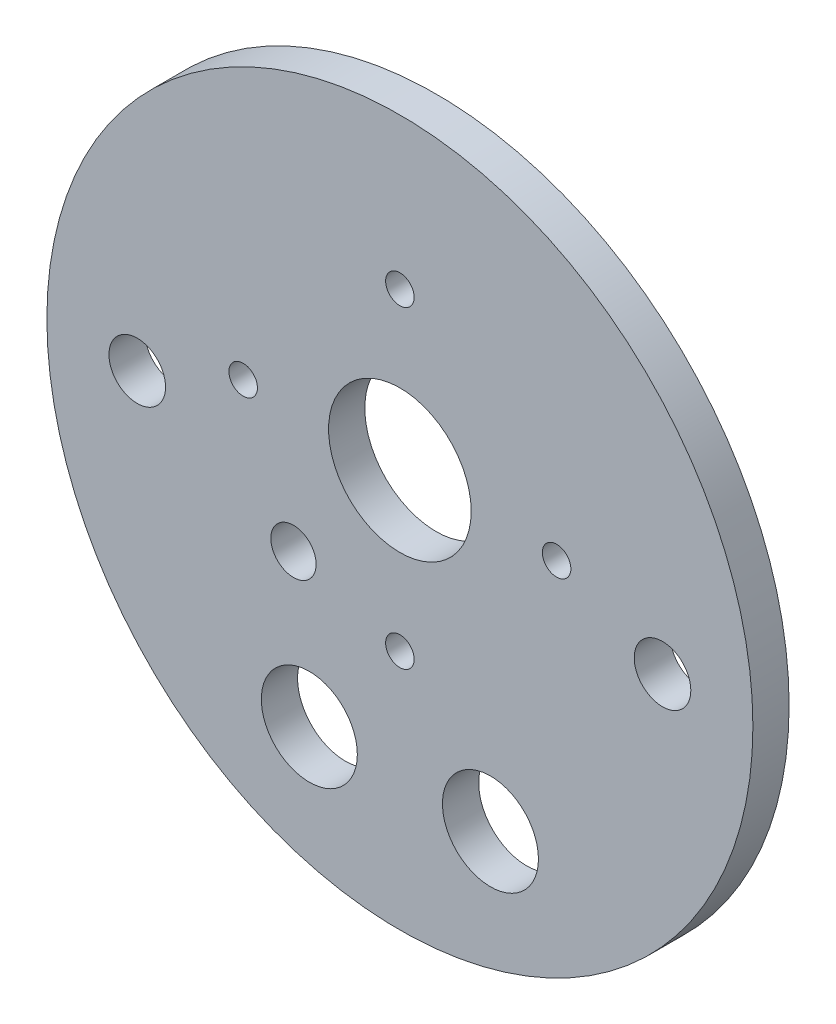
from build123d import *

# Parameters (mm, degrees)
SKETCH1_R           = 49.5046
BOSS_EXTRUDE1_DEPTH = 5.08
SKETCH2_R           = 47.625
BOSS_EXTRUDE2_DEPTH = 3.175
SKETCH3_R           = 6.731
SKETCH3_R_2         = 3.96875
SKETCH3_R_3         = 10
SKETCH3_R_4         = 3.175
SKETCH3_R_5         = 2
CUT_EXTRUDE1_DEPTH  = 9.255
SKETCH7_R           = 56.423127019
CUT_EXTRUDE2_DEPTH  = 3.175


with BuildPart() as part:
    # Sketch1 → Boss-Extrude1 (new body)
    with BuildSketch(Plane.XY):
        Circle(SKETCH1_R)
    extrude(amount=BOSS_EXTRUDE1_DEPTH)

    # Sketch2 → Boss-Extrude2 (add)
    with BuildSketch(Plane.XY.offset(5.08)):
        Circle(SKETCH2_R)
    extrude(amount=BOSS_EXTRUDE2_DEPTH)

    # Sketch3 → Cut-Extrude1 (cut, through all)
    with BuildSketch(Plane.XY.offset(8.255)):
        with Locations((-12.7, -31.166793627)):
            Circle(SKETCH3_R)
        with Locations((12.7, -31.166793627)):
            Circle(SKETCH3_R)
        with Locations((-36.83, 0)):
            Circle(SKETCH3_R_2)
        with Locations((36.83, 0)):
            Circle(SKETCH3_R_2)
        with Locations((0, 6.35)):
            Circle(SKETCH3_R_3)
        with Locations((-14.921345457, -10.968575281)):
            Circle(SKETCH3_R_4)
        with Locations((0, 28.326878759)):
            Circle(SKETCH3_R_5)
        with Locations((21.976878759, 6.35)):
            Circle(SKETCH3_R_5)
        with Locations((0, -15.626878759)):
            Circle(SKETCH3_R_5)
        with Locations((-21.976878759, 6.35)):
            Circle(SKETCH3_R_5)
    extrude(amount=-CUT_EXTRUDE1_DEPTH, mode=Mode.SUBTRACT)

    # Sketch7 → Cut-Extrude2 (cut)
    with BuildSketch(Plane.XY.offset(8.255)):
        Circle(SKETCH7_R)
    extrude(amount=-CUT_EXTRUDE2_DEPTH, mode=Mode.SUBTRACT)


solid = part.part
